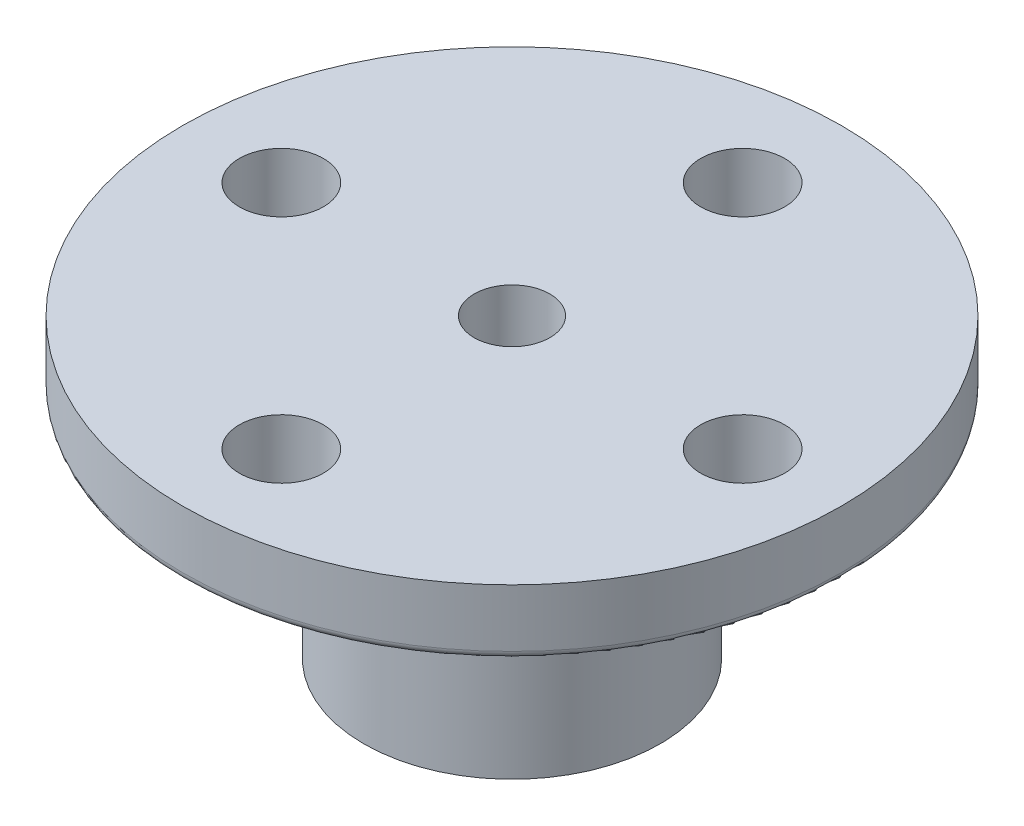
from build123d import *

# Parameters (mm, degrees)
SKETCH1_R           = 10
BOSS_EXTRUDE1_DEPTH = 2
SKETCH2_R           = 4.5
BOSS_EXTRUDE2_DEPTH = 7
SKETCH3_R           = 1.275
CUT_EXTRUDE1_DEPTH  = 3
FILLET1_R           = 0.25
SKETCH6_R           = 1.15
CUT_EXTRUDE2_DEPTH  = 10
SKETCH7_R           = 3.25
CUT_EXTRUDE3_DEPTH  = 2.5
BOSS_EXTRUDE4_DEPTH = 2.5
CIRPATTERN1_COUNT   = 26


with BuildPart() as part:
    # Sketch1 → Boss-Extrude1 (new body)
    with BuildSketch(Plane(origin=(0, 0, 0), x_dir=(1, 0, 0), z_dir=(0, 1, 0))):
        Circle(SKETCH1_R)
    extrude(amount=BOSS_EXTRUDE1_DEPTH)

    # Sketch2 → Boss-Extrude2 (add)
    with BuildSketch(Plane(origin=(0, 0, 0), x_dir=(1, 0, 0), z_dir=(0, 1, 0))):
        Circle(SKETCH2_R)
    extrude(amount=-BOSS_EXTRUDE2_DEPTH)

    # Sketch3 → Cut-Extrude1 (cut, through all)
    with BuildSketch(Plane(origin=(0, 0, 0), x_dir=(1, 0, 0), z_dir=(0, 1, 0))):
        with Locations((0, 7)):
            Circle(SKETCH3_R)
        with Locations((-7, 0)):
            Circle(SKETCH3_R)
        with Locations((0, -7)):
            Circle(SKETCH3_R)
        with Locations((7, 0)):
            Circle(SKETCH3_R)
    extrude(amount=CUT_EXTRUDE1_DEPTH, mode=Mode.SUBTRACT)

    # Fillet1
    fillet1_edges = [part.edges().sort_by_distance(p)[0] for p in [
        (-10, 0, 0),
    ]]
    fillet(fillet1_edges, radius=FILLET1_R)

    # Sketch6 → Cut-Extrude2 (cut, through all)
    with BuildSketch(Plane(origin=(0, 2, 0), x_dir=(1, 0, 0), z_dir=(0, 1, 0))):
        Circle(SKETCH6_R)
    extrude(amount=-CUT_EXTRUDE2_DEPTH, mode=Mode.SUBTRACT)

    # Sketch7 → Cut-Extrude3 (cut)
    with BuildSketch(Plane.XZ.offset(7)):
        Circle(SKETCH7_R)
    extrude(amount=-CUT_EXTRUDE3_DEPTH, mode=Mode.SUBTRACT)

    # Sketch8 → Boss-Extrude4 (add)
    with BuildSketch(Plane.XZ.offset(7)):
        with BuildLine():
            Line((-2.67824125, -1.107011583), (-3.073819571, -1.003017967))
            ThreePointArc((-3.073819571, -1.003017967), (-2.972382473, -1.245868077), (-2.849346423, -1.478521878))
            Line((-2.849346423, -1.478521878), (-2.67824125, -1.107011583))
        make_face()
    boss_extrude4 = extrude(amount=-BOSS_EXTRUDE4_DEPTH)

    # CirPattern1: Boss-Extrude4 ×26 about axis
    cirpattern1_axis = Axis((0, 0, 0), (0, 1, 0))
    for i in range(1, CIRPATTERN1_COUNT):
        add(boss_extrude4.rotate(cirpattern1_axis, i * 360 / CIRPATTERN1_COUNT))


solid = part.part
